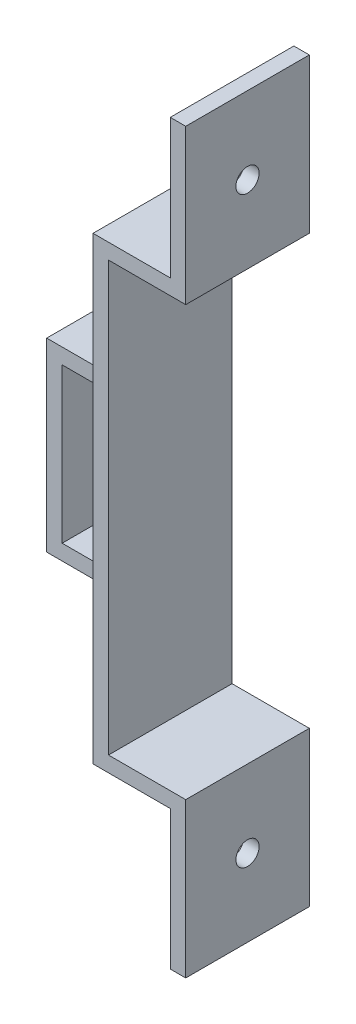
from build123d import *

# Parameters (mm, degrees)
Y_KSEKLIK_EKSTR_ZYON1_DEPTH = 8
IZIM2_R                     = 1.5
KES_EKSTR_ZYON1_DEPTH       = 10
Y_KSEKLIK_EKSTR_ZYON2_DEPTH = 5


with BuildPart() as part:
    # Çizim1 → Yükseklik-Ekstrüzyon1 (new body, symmetric)
    with BuildSketch(Plane.XY):
        Polygon((-15, 27.75), (-13, 27.75), (-13, 29.75), (-13, 47.75), (-15, 47.75), (-15, 29.75), (-25, 29.75), (-25, -29.75), (-15, -29.75), (-15, -47.75), (-13, -47.75), (-13, -29.75), (-13, -27.75), (-15, -27.75), (-23, -27.75), (-23, 0), (-23, 27.75), align=None)
    extrude(amount=Y_KSEKLIK_EKSTR_ZYON1_DEPTH, both=True)

    # Çizim2 → Kes-Ekstrüzyon1 (cut)
    with BuildSketch(Plane.ZY.offset(15)):
        with Locations((0, 37.75)):
            Circle(IZIM2_R)
        with Locations((0, -37.75)):
            Circle(IZIM2_R)
    extrude(amount=-KES_EKSTR_ZYON1_DEPTH, mode=Mode.SUBTRACT)

    # Çizim4 → Yükseklik-Ekstrüzyon2 (add, symmetric)
    with BuildSketch(Plane.XY):
        Polygon((-25, 10), (-32, 10), (-32, -10), (-25, -10), (-25, -12), (-34, -12), (-34, 12), (-25, 12), align=None)
    extrude(amount=Y_KSEKLIK_EKSTR_ZYON2_DEPTH, both=True)


solid = part.part
